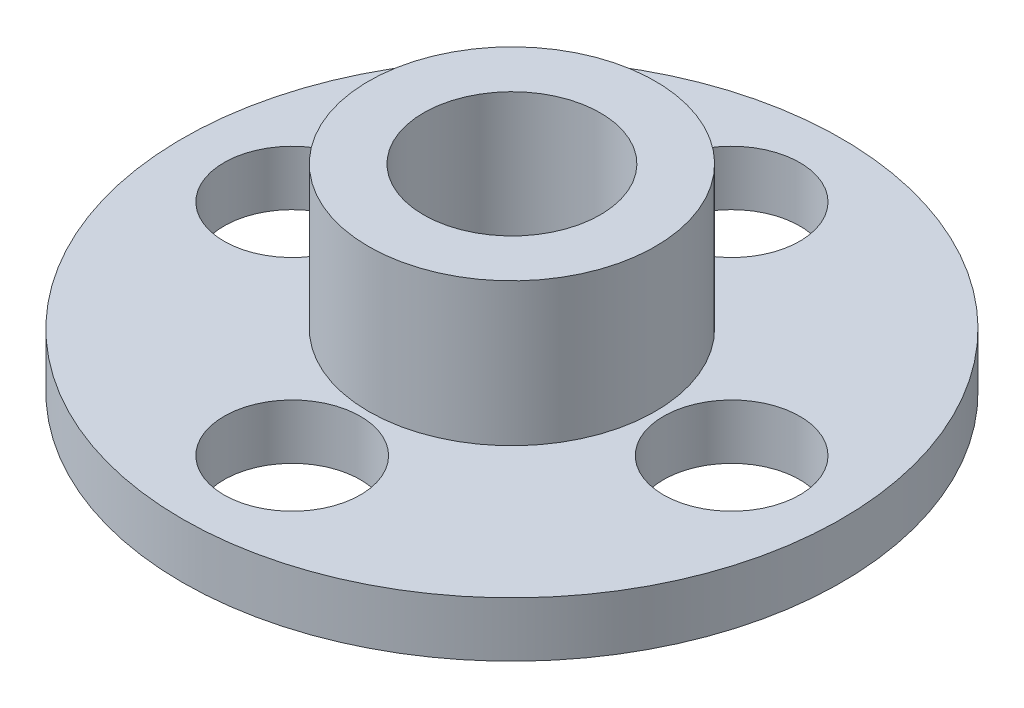
from build123d import *

# Parameters (mm, degrees)
SKETCH1_R           = 19.05
SKETCH1_R_2         = 5.08
SKETCH1_R_3         = 3.940198068
BOSS_EXTRUDE1_DEPTH = 3.175
SKETCH2_R           = 8.284256576
SKETCH2_R_2         = 5.109256576
BOSS_EXTRUDE2_DEPTH = 8.255


with BuildPart() as part:
    # Sketch1 → Boss-Extrude1 (new body)
    with BuildSketch(Plane(origin=(0, 0, 0), x_dir=(1, 0, 0), z_dir=(0, 1, 0))):
        Circle(SKETCH1_R)
        Circle(SKETCH1_R_2, mode=Mode.SUBTRACT)
        with Locations((0, 12.7)):
            Circle(SKETCH1_R_3, mode=Mode.SUBTRACT)
        with Locations((12.7, 0)):
            Circle(SKETCH1_R_3, mode=Mode.SUBTRACT)
        with Locations((0, -12.7)):
            Circle(SKETCH1_R_3, mode=Mode.SUBTRACT)
        with Locations((-12.7, 0)):
            Circle(SKETCH1_R_3, mode=Mode.SUBTRACT)
    extrude(amount=BOSS_EXTRUDE1_DEPTH)

    # Sketch2 → Boss-Extrude2 (add)
    with BuildSketch(Plane(origin=(0, 3.175, 0), x_dir=(1, 0, 0), z_dir=(0, 1, 0))):
        Circle(SKETCH2_R)
        Circle(SKETCH2_R_2, mode=Mode.SUBTRACT)
    extrude(amount=BOSS_EXTRUDE2_DEPTH)


solid = part.part
